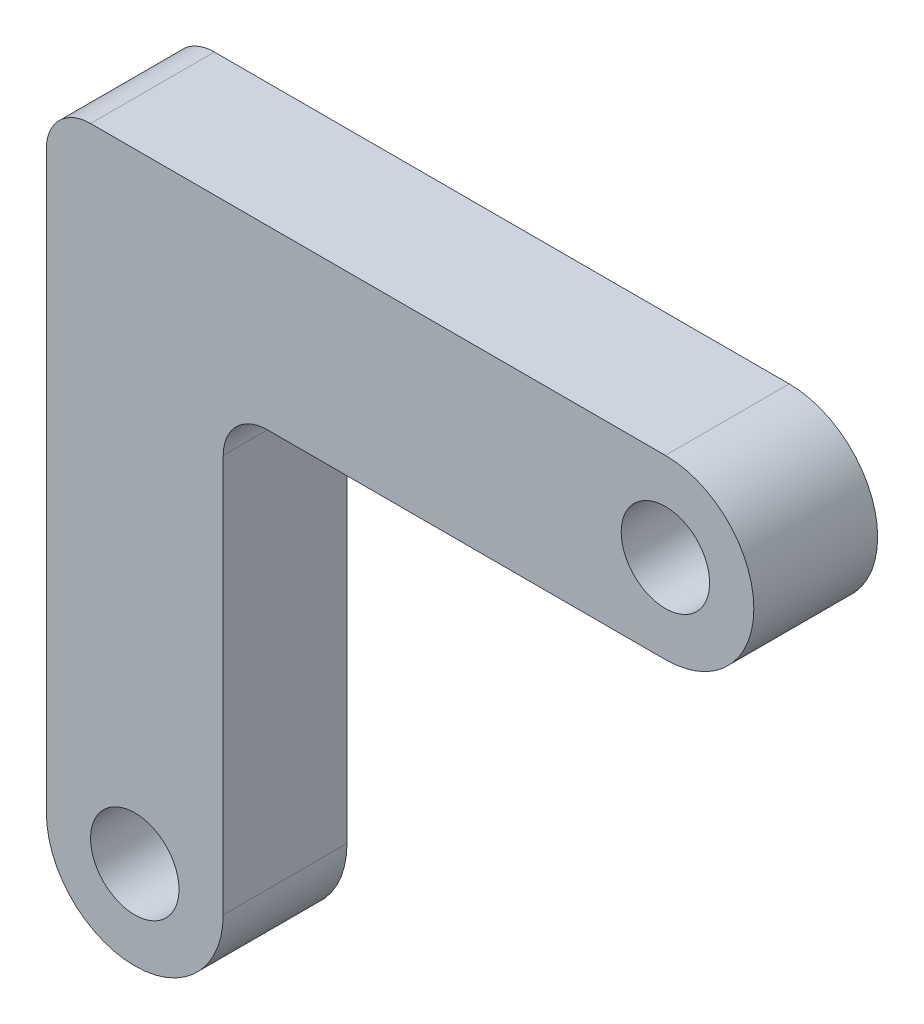
from build123d import *

# Parameters (mm, degrees)
SKETCH1_R           = 1
BOSS_EXTRUDE2_DEPTH = 2.8
FILLET1_R           = 1


with BuildPart() as part:
    # Sketch1 → Boss-Extrude2 (new body)
    with BuildSketch(Plane.XY):
        with BuildLine():
            Line((-0.910186913, 0.71299639), (-0.910186913, 14.71299639))
            Line((-0.910186913, 14.71299639), (13.089813087, 14.71299639))
            ThreePointArc((13.089813087, 14.71299639), (15.089813087, 12.71299639), (13.089813087, 10.71299639))
            Line((13.089813087, 10.71299639), (3.089813087, 10.71299639))
            Line((3.089813087, 10.71299639), (3.089813087, 0.71299639))
            ThreePointArc((3.089813087, 0.71299639), (1.089813087, -1.28700361), (-0.910186913, 0.71299639))
        make_face()
        with Locations((1.089813087, 0.71299639)):
            Circle(SKETCH1_R, mode=Mode.SUBTRACT)
        with Locations((13.089813087, 12.71299639)):
            Circle(SKETCH1_R, mode=Mode.SUBTRACT)
    extrude(amount=BOSS_EXTRUDE2_DEPTH)

    # Fillet1
    fillet1_edges = [part.edges().sort_by_distance(p)[0] for p in [
        (3.089813087, 10.71299639, 1.4),
        (-0.910186913, 14.71299639, 1.4),
    ]]
    fillet(fillet1_edges, radius=FILLET1_R)


solid = part.part
